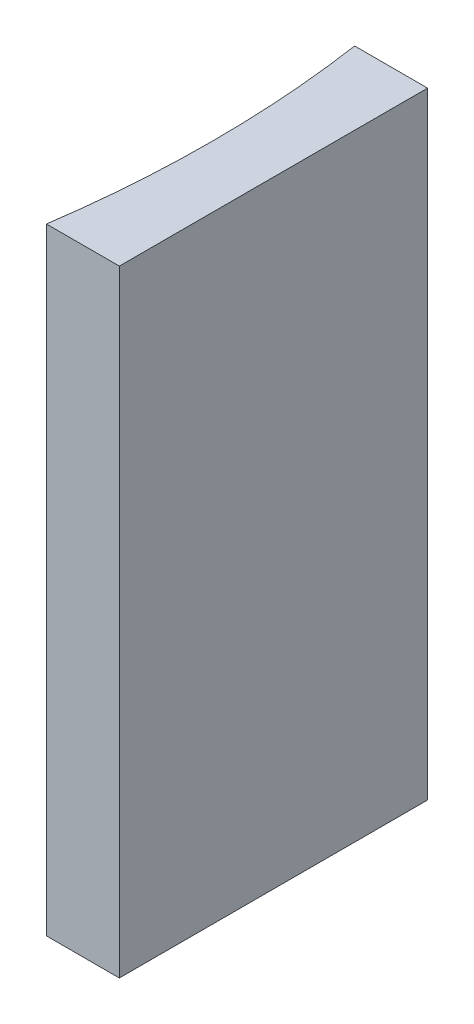
from build123d import *

# Parameters (mm, degrees)
EXTRUDE_1_DEPTH = 20


with BuildPart() as part:
    # 草图1 → 凸台-拉伸1 (new body)
    with BuildSketch(Plane(origin=(0, 0, 0), x_dir=(1, 0, 0), z_dir=(0, 1, 0))):
        with BuildLine():
            Line((0, 0), (0, -10))
            Line((0, -10), (-2.365849282, -10))
            ThreePointArc((-2.365849282, -10), (-2, -5), (-2.365849282, 0))
            Line((-2.365849282, 0), (0, 0))
        make_face()
    extrude(amount=EXTRUDE_1_DEPTH)


solid = part.part
